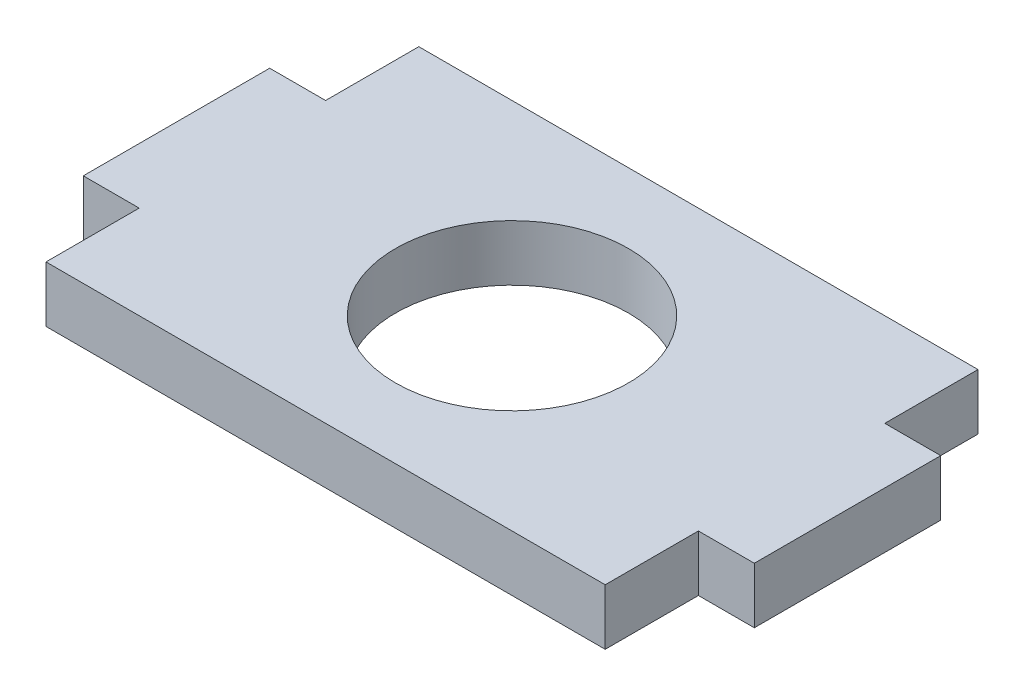
from build123d import *

# Parameters (mm, degrees)
SKETCH1_R           = 6.25
BOSS_EXTRUDE1_DEPTH = 3


with BuildPart() as part:
    # Sketch1 → Boss-Extrude1 (new body)
    with BuildSketch(Plane(origin=(0, 0, 0), x_dir=(1, 0, 0), z_dir=(0, 1, 0))):
        Polygon((-15, 10), (-15, 5), (-18, 5), (-18, -5), (-15, -5), (-15, -10), (15, -10), (15, -5), (18, -5), (18, 5), (15, 5), (15, 10), align=None)
        Circle(SKETCH1_R, mode=Mode.SUBTRACT)
    extrude(amount=BOSS_EXTRUDE1_DEPTH)


solid = part.part
